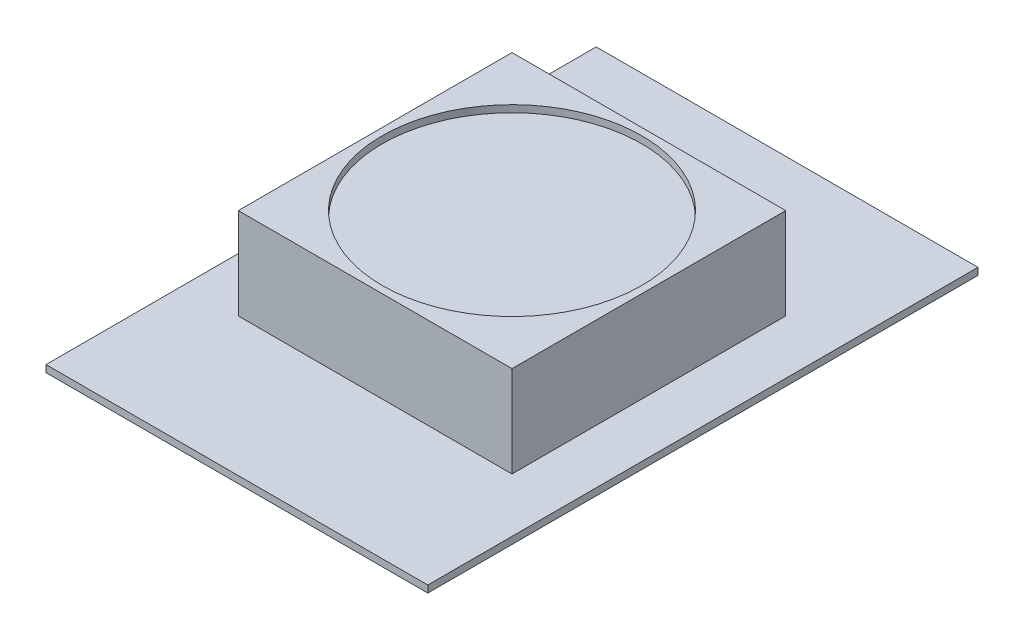
from build123d import *

# Parameters (mm, degrees)
SKETCH1_W           = 6.9088
SKETCH1_H           = 9.9568
BOSS_EXTRUDE1_DEPTH = 0.127
SKETCH3_W           = 4.953
SKETCH3_H           = 4.953
BOSS_EXTRUDE3_DEPTH = 1.651
SKETCH5_R           = 2.348345572
CUT_EXTRUDE1_DEPTH  = 0.127


with BuildPart() as part:
    # Sketch1 → Boss-Extrude1 (new body)
    with BuildSketch(Plane(origin=(0, 0, 0), x_dir=(1, 0, 0), z_dir=(0, 1, 0))):
        Rectangle(SKETCH1_W, SKETCH1_H)
    extrude(amount=BOSS_EXTRUDE1_DEPTH)

    # Sketch3 → Boss-Extrude3 (add)
    with BuildSketch(Plane(origin=(0, 0.127, 0), x_dir=(1, 0, 0), z_dir=(0, 1, 0))):
        Rectangle(SKETCH3_W, SKETCH3_H)
    extrude(amount=BOSS_EXTRUDE3_DEPTH)

    # Sketch5 → Cut-Extrude1 (cut)
    with BuildSketch(Plane(origin=(0, 1.778, 0), x_dir=(1, 0, 0), z_dir=(0, 1, 0))):
        Circle(SKETCH5_R)
    extrude(amount=-CUT_EXTRUDE1_DEPTH, mode=Mode.SUBTRACT)


solid = part.part
